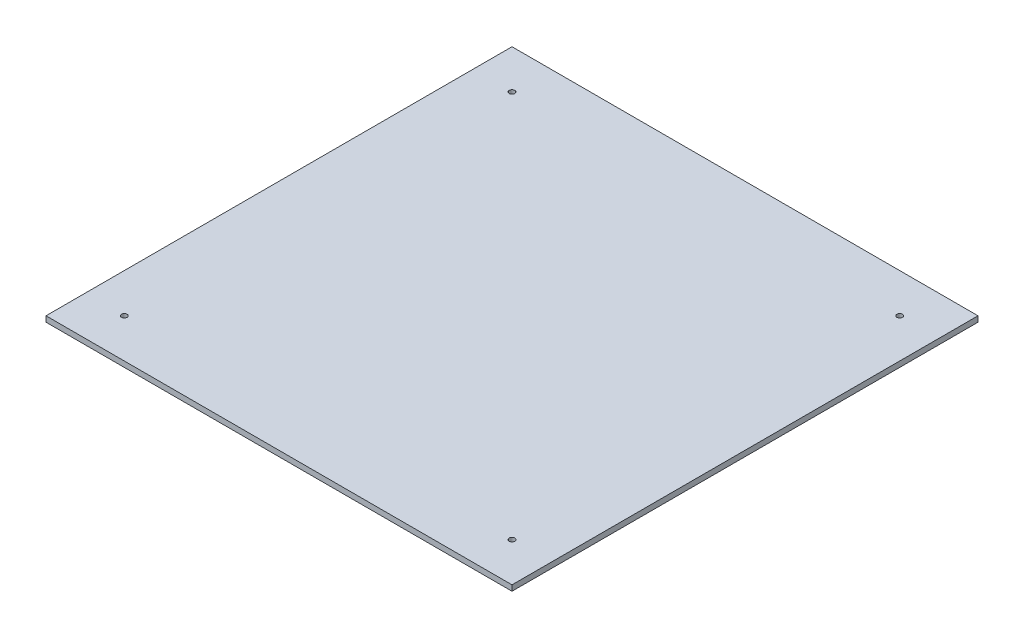
from build123d import *

# Parameters (mm, degrees)
ESBO_O1_W                = 250
ESBO_O1_H                = 250
ESBO_O1_R                = 1.5
RESSALTO_EXTRUS_O1_DEPTH = 3


with BuildPart() as part:
    # Esboço1 → Ressalto-extrusão1 (new body)
    with BuildSketch(Plane(origin=(0, 0, 0), x_dir=(1, 0, 0), z_dir=(0, 1, 0))):
        Rectangle(ESBO_O1_W, ESBO_O1_H)
        with Locations((-104, 104)):
            Circle(ESBO_O1_R, mode=Mode.SUBTRACT)
        with Locations((-104, -104)):
            Circle(ESBO_O1_R, mode=Mode.SUBTRACT)
        with Locations((104, -104)):
            Circle(ESBO_O1_R, mode=Mode.SUBTRACT)
        with Locations((104, 104)):
            Circle(ESBO_O1_R, mode=Mode.SUBTRACT)
    extrude(amount=RESSALTO_EXTRUS_O1_DEPTH)


solid = part.part
